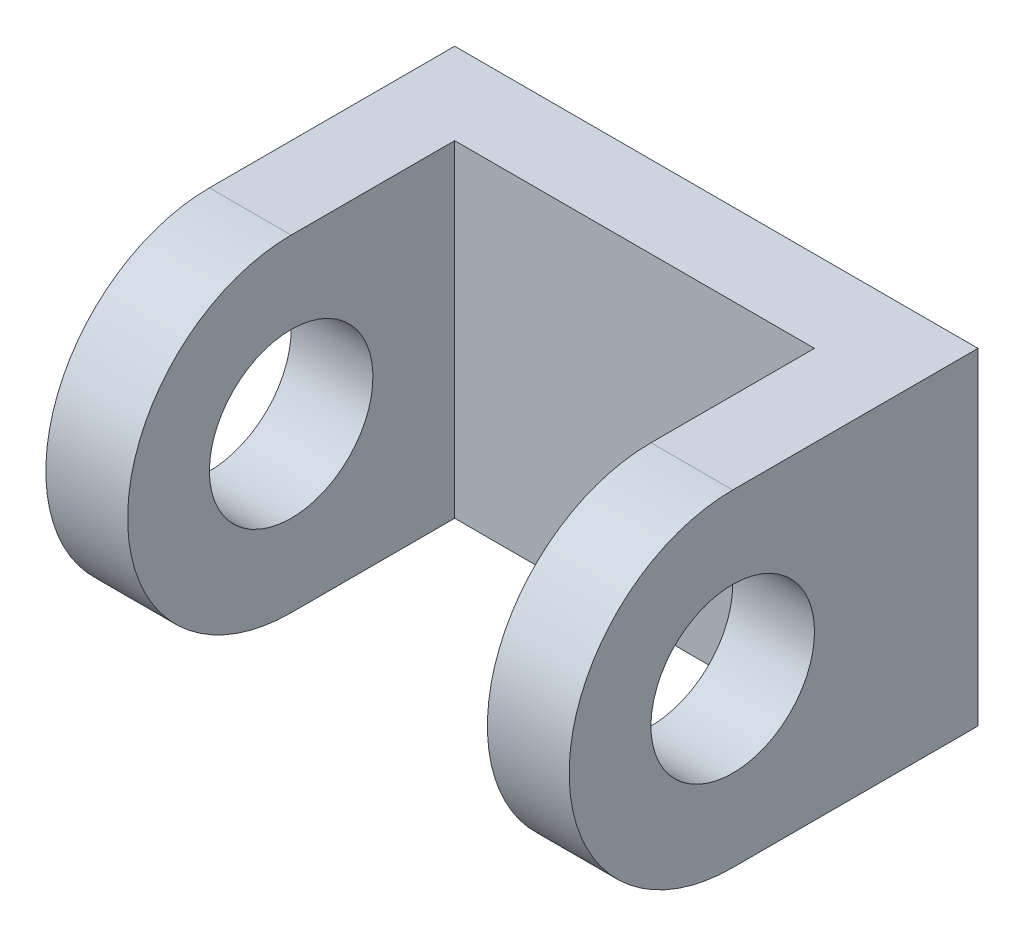
from build123d import *

# Parameters (mm, degrees)
SKETCH1_W           = 40.64
SKETCH1_H           = 25.4
BOSS_EXTRUDE1_DEPTH = 31.75
SKETCH3_W           = 27.94
SKETCH3_H           = 25.4
CUT_EXTRUDE1_DEPTH  = 26.4
SKETCH4_R           = 6.35
CUT_EXTRUDE2_DEPTH  = 41.64
CUT_EXTRUDE3_DEPTH  = 41.64


with BuildPart() as part:
    # Sketch1 → Boss-Extrude1 (new body)
    with BuildSketch(Plane.XY):
        Rectangle(SKETCH1_W, SKETCH1_H)
    extrude(amount=BOSS_EXTRUDE1_DEPTH)

    # Sketch3 → Cut-Extrude1 (cut, through all)
    with BuildSketch(Plane(origin=(0, 12.7, 0), x_dir=(1, 0, 0), z_dir=(0, 1, 0))):
        with Locations((0, -19.05)):
            Rectangle(SKETCH3_W, SKETCH3_H)
    extrude(amount=-CUT_EXTRUDE1_DEPTH, mode=Mode.SUBTRACT)

    # Sketch4 → Cut-Extrude2 (cut, through all)
    with BuildSketch(Plane(origin=(20.32, 0, 0), x_dir=(0, 0, -1), z_dir=(1, 0, 0))):
        with Locations(Location((-19.05, 0, 0), (0, 0, 90))):  # turned: the seam where the file's is
            Circle(SKETCH4_R)
    extrude(amount=-CUT_EXTRUDE2_DEPTH, mode=Mode.SUBTRACT)

    # Sketch5 → Cut-Extrude3 (cut, through all)
    with BuildSketch(Plane(origin=(20.32, 0, 0), x_dir=(0, 0, -1), z_dir=(1, 0, 0))):
        with BuildLine():
            Line((-31.75, 12.7), (-19.05, 12.7))
            ThreePointArc((-19.05, 12.7), (-28.030256121, 8.980256121), (-31.75, 0))
            Line((-31.75, 0), (-31.75, 12.7))
        make_face()
    cut_extrude3 = extrude(amount=-CUT_EXTRUDE3_DEPTH, mode=Mode.SUBTRACT)

    # Mirror1: Cut-Extrude3 across plane
    add(cut_extrude3.mirror(Plane.ZX), mode=Mode.SUBTRACT)


solid = part.part
